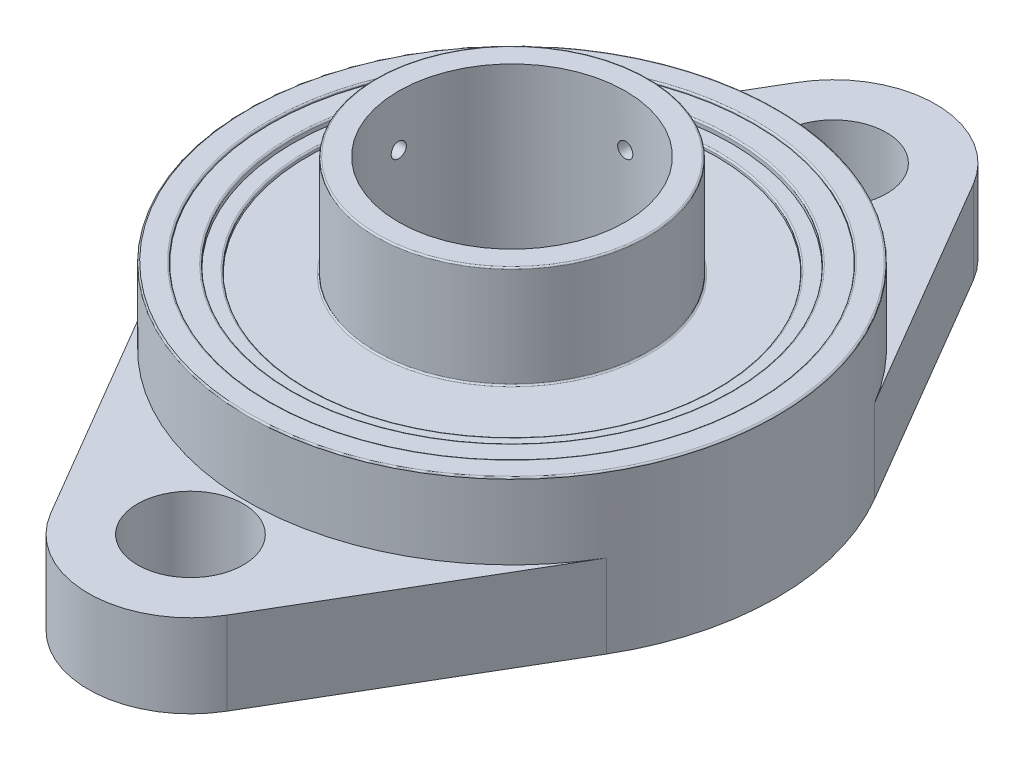
from build123d import *

# Parameters (mm, degrees)
SKETCH1_R             = 7
SKETCH1_R_2           = 32
EXTRUDE_A1_DEPTH      = 11
SKETCH1_3_R           = 32
EXTRUDE_A_DEPTH       = 21
SKETCH1_4_R           = 18
SKETCH1_4_R_2         = 15
EXTRUDE_A0_DEPTH      = 33
BEARING_START         = 2
SKETCH1_7_R           = 29
SKETCH1_7_R_2         = 27
BEARING_OUTER_D_DEPTH = 18
BOSS_EXTRUDE6_START   = 1.2
SKETCH1_8_R           = 32
SKETCH1_8_R_2         = 29
BOSS_EXTRUDE6_DEPTH   = 19.5
BOSS_EXTRUDE7_START   = 1.5
SKETCH1_9_R           = 27
SKETCH1_9_R_2         = 18
BOSS_EXTRUDE7_DEPTH   = 18
CUT_EXTRUDE1_REACH    = 75.824
SKETCH2_R             = 1
CUT_EXTRUDE2_REACH    = 75.824
SKETCH3_R             = 1
FILLET1_R             = 0.2
FILLET2_R             = 0.2


with BuildPart() as part:
    # Sketch1 → Extrude A1 (new body)
    with BuildSketch(Plane(origin=(0, 0, 0), x_dir=(1, 0, 0), z_dir=(0, 1, 0))):
        with BuildLine():
            Line((11.645133531, -49.329411765), (30.191086931, -17.705882353))
            ThreePointArc((30.191086931, -17.705882353), (35, 0), (30.191086931, 17.705882353))
            Line((30.191086931, 17.705882353), (11.645133531, 49.329411765))
            ThreePointArc((11.645133531, 49.329411765), (0, 56), (-11.645133531, 49.329411765))
            Line((-11.645133531, 49.329411765), (-30.191086931, 17.705882353))
            ThreePointArc((-30.191086931, 17.705882353), (-35, 0), (-30.191086931, -17.705882353))
            Line((-30.191086931, -17.705882353), (-11.645133531, -49.329411765))
            ThreePointArc((-11.645133531, -49.329411765), (0, -56), (11.645133531, -49.329411765))
        make_face()
        with Locations((0, -42.5)):
            Circle(SKETCH1_R, mode=Mode.SUBTRACT)
        Circle(SKETCH1_R_2, mode=Mode.SUBTRACT)
        with Locations((0, 42.5)):
            Circle(SKETCH1_R, mode=Mode.SUBTRACT)
    extrude(amount=EXTRUDE_A1_DEPTH)

    # Sketch1_3 → Extrude A (add)
    with BuildSketch(Plane(origin=(0, 0, 0), x_dir=(1, 0, 0), z_dir=(0, 1, 0))):
        with BuildLine():
            ThreePointArc((-30.191086931, -17.705882353), (0, -35), (30.191086931, -17.705882353))
            ThreePointArc((30.191086931, -17.705882353), (33.776382596, -9.173656779), (35, 0))
            ThreePointArc((35, 0), (33.776382596, 9.173656779), (30.191086931, 17.705882353))
            ThreePointArc((30.191086931, 17.705882353), (0, 35), (-30.191086931, 17.705882353))
            ThreePointArc((-30.191086931, 17.705882353), (-35, 0), (-30.191086931, -17.705882353))
        make_face()
        Circle(SKETCH1_3_R, mode=Mode.SUBTRACT)
    extrude(amount=EXTRUDE_A_DEPTH)



with BuildPart() as body_2:
    # Sketch1_4 → Extrude A0 (new body)
    with BuildSketch(Plane(origin=(0, 0, 0), x_dir=(1, 0, 0), z_dir=(0, 1, 0))):
        Circle(SKETCH1_4_R)
        Circle(SKETCH1_4_R_2, mode=Mode.SUBTRACT)
    extrude(amount=EXTRUDE_A0_DEPTH)


with BuildPart() as body_3:
    # Sketch1_7 → Bearing outer d (new body)
    with BuildSketch(Plane(origin=(0, 0, 0), x_dir=(1, 0, 0), z_dir=(0, 1, 0)).offset(BEARING_START)):
        Circle(SKETCH1_7_R)
        Circle(SKETCH1_7_R_2, mode=Mode.SUBTRACT)
    extrude(amount=BEARING_OUTER_D_DEPTH)


with BuildPart() as part_1:
    add(part.part)

    add(body_3.part)  # Boss-Extrude6 merges body 3
    # Sketch1_8 → Boss-Extrude6 (add)
    with BuildSketch(Plane(origin=(0, 0, 0), x_dir=(1, 0, 0), z_dir=(0, 1, 0)).offset(BOSS_EXTRUDE6_START)):
        Circle(SKETCH1_8_R)
        Circle(SKETCH1_8_R_2, mode=Mode.SUBTRACT)
    extrude(amount=BOSS_EXTRUDE6_DEPTH)


    add(body_2.part)  # Boss-Extrude7 merges body 2
    # Sketch1_9 → Boss-Extrude7 (add)
    with BuildSketch(Plane(origin=(0, 0, 0), x_dir=(1, 0, 0), z_dir=(0, 1, 0)).offset(BOSS_EXTRUDE7_START)):
        Circle(SKETCH1_9_R)
        Circle(SKETCH1_9_R_2, mode=Mode.SUBTRACT)
    extrude(amount=BOSS_EXTRUDE7_DEPTH)

    # Sketch2 → Cut-Extrude1 (cut, up to next)
    with BuildSketch(Plane(origin=(0, 0, 0), x_dir=(0, 0, -1), z_dir=(1, 0, 0)), mode=Mode.PRIVATE) as cut_extrude1_sk1:
        with Locations((0, 26.25)):
            Circle(SKETCH2_R)
    cut_extrude1_tool1 = extrude(cut_extrude1_sk1.sketch, amount=-CUT_EXTRUDE1_REACH, mode=Mode.PRIVATE) & part_1.part
    add(cut_extrude1_tool1.solids().sort_by_distance((0, 26.25, 0))[0], mode=Mode.SUBTRACT)

    # Sketch3 → Cut-Extrude2 (cut, up to next)
    with BuildSketch(Plane.XY, mode=Mode.PRIVATE) as cut_extrude2_sk1:
        with Locations((0, 26.25)):
            Circle(SKETCH3_R)
    cut_extrude2_tool1 = extrude(cut_extrude2_sk1.sketch, amount=-CUT_EXTRUDE2_REACH, mode=Mode.PRIVATE) & part_1.part
    add(cut_extrude2_tool1.solids().sort_by_distance((0, 26.25, 0))[0], mode=Mode.SUBTRACT)

    # Fillet1
    fillet1_edges = [part_1.edges().sort_by_distance(p)[0] for p in [
        (-27, 20, 0),
    ]]
    fillet(fillet1_edges, radius=FILLET1_R)

    # Fillet2
    fillet2_edges = [part_1.edges().sort_by_distance(p)[0] for p in [
        (-18, 33, 0),
        (-18, 19.5, 0),
        (-30.191086931, 21, 17.705882353),
        (-32, 21, 0),
        (-29, 20.7, 0),
    ]]
    fillet(fillet2_edges, radius=FILLET2_R)


solid = part_1.part
